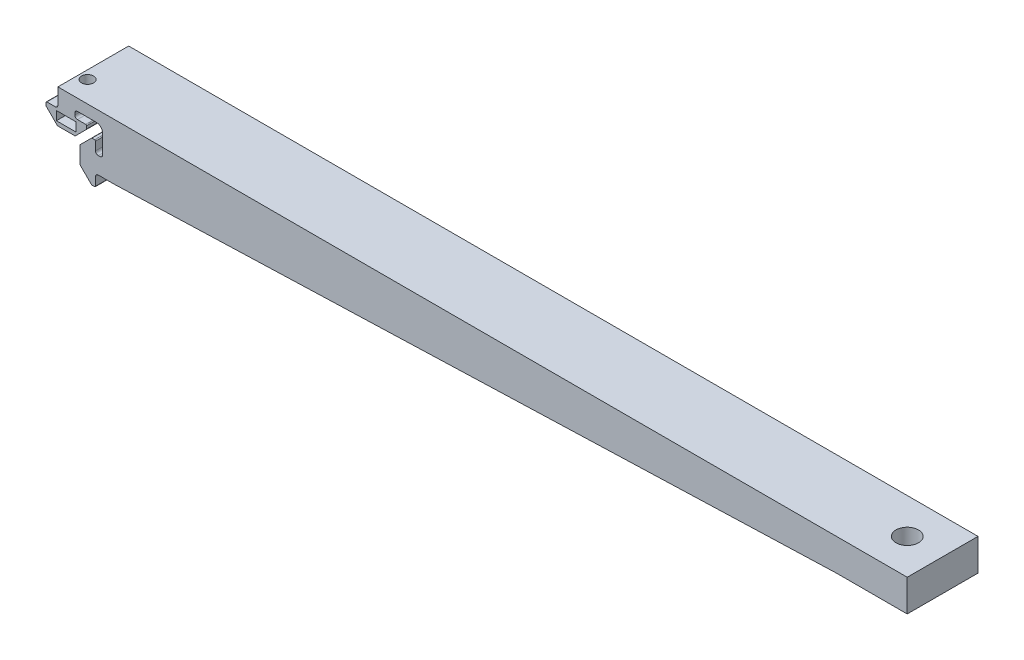
from build123d import *

# Parameters (mm, degrees)
BOSS_EXTRUDE1_DEPTH = 20
BOSS_EXTRUDE2_DEPTH = 20
CUT_EXTRUDE1_DEPTH  = 20
SKETCH4_R           = 3.175
CUT_EXTRUDE2_DEPTH  = 4
SKETCH5_W           = 20
SKETCH5_H           = 20
SKETCH5_R           = 3.175
BOSS_EXTRUDE3_DEPTH = 5
BOSS_EXTRUDE4_DEPTH = 20
CUT_EXTRUDE3_START  = -6
CUT_EXTRUDE3_DEPTH  = 2.5
SKETCH9_R           = 1.7
CUT_EXTRUDE4_DEPTH  = 20.237


with BuildPart() as part:
    # Sketch1 → Boss-Extrude1 (new body)
    with BuildSketch(Plane.XY):
        with BuildLine():
            ThreePointArc((-3.138, 8.25), (-2.60201306, 8.47201306), (-2.38, 9.008))
            Line((-2.38, 9.008), (-2.38, 9.492))
            Line((-2.38, 9.492), (-2.38, 13.492))
            Line((-2.38, 13.492), (13.492, 13.492))
            Line((13.492, 13.492), (13.492, -2.38))
            Line((13.492, -2.38), (9.492, -2.38))
            Line((9.492, -2.38), (9.008, -2.38))
            ThreePointArc((9.008, -2.38), (8.47201306, -2.60201306), (8.25, -3.138))
            Line((8.25, -3.138), (8.25, -5.487))
            ThreePointArc((8.25, -5.487), (8.17443355, -5.66943355), (7.992, -5.745))
            Line((7.992, -5.745), (7.266240833, -5.745))
            ThreePointArc((7.266240833, -5.745), (7.167508508, -5.725360919), (7.083807284, -5.66943355))
            Line((7.083807284, -5.66943355), (3.98056645, -2.566192716))
            ThreePointArc((3.98056645, -2.566192716), (3.924639081, -2.482491492), (3.905, -2.383759167))
            Line((3.905, -2.383759167), (3.905, 2.38407951))
            ThreePointArc((3.905, 2.38407951), (3.924639081, 2.482811836), (3.98056645, 2.56651306))
            Line((3.98056645, 2.56651306), (7.08348694, 5.66943355))
            ThreePointArc((7.08348694, 5.66943355), (7.167188164, 5.725360919), (7.26592049, 5.745))
            Line((7.26592049, 5.745), (7.992, 5.745))
            ThreePointArc((7.992, 5.745), (8.17443355, 5.66943355), (8.25, 5.487))
            Line((8.25, 5.487), (8.25, 3.138))
            ThreePointArc((8.25, 3.138), (8.47201306, 2.60201306), (9.008, 2.38))
            Line((9.008, 2.38), (9.492, 2.38))
            ThreePointArc((9.492, 2.38), (10.02798694, 2.60201306), (10.25, 3.138))
            Line((10.25, 3.138), (10.25, 8.5))
            ThreePointArc((10.25, 8.5), (9.737436867, 9.737436867), (8.5, 10.25))
            Line((8.5, 10.25), (3.138, 10.25))
            ThreePointArc((3.138, 10.25), (2.60201306, 10.02798694), (2.38, 9.492))
            Line((2.38, 9.492), (2.38, 9.008))
            ThreePointArc((2.38, 9.008), (2.60201306, 8.47201306), (3.138, 8.25))
            Line((3.138, 8.25), (5.487, 8.25))
            ThreePointArc((5.487, 8.25), (5.66943355, 8.17443355), (5.745, 7.992))
            Line((5.745, 7.992), (5.745, 7.266240833))
            ThreePointArc((5.745, 7.266240833), (5.725360919, 7.167508508), (5.66943355, 7.083807284))
            Line((5.66943355, 7.083807284), (2.566192716, 3.98056645))
            ThreePointArc((2.566192716, 3.98056645), (2.482491492, 3.924639081), (2.383759167, 3.905))
            Line((2.383759167, 3.905), (-2.38407951, 3.905))
            ThreePointArc((-2.38407951, 3.905), (-2.482811836, 3.924639081), (-2.56651306, 3.98056645))
            Line((-2.56651306, 3.98056645), (-5.66943355, 7.08348694))
            ThreePointArc((-5.66943355, 7.08348694), (-5.725360919, 7.167188164), (-5.745, 7.26592049))
            Line((-5.745, 7.26592049), (-5.745, 7.992))
            ThreePointArc((-5.745, 7.992), (-5.66943355, 8.17443355), (-5.487, 8.25))
            Line((-5.487, 8.25), (-3.138, 8.25))
        make_face()
    extrude(amount=-BOSS_EXTRUDE1_DEPTH)

    # Sketch2 → Boss-Extrude2 (add)
    with BuildSketch(Plane.XY):
        Polygon((13.492, 13.492), (237.62, 13.492), (237.62, 9.492), (13.492, -2.38), align=None)
    extrude(amount=-BOSS_EXTRUDE2_DEPTH)

    # Sketch3 → Cut-Extrude1 (cut)
    with BuildSketch(Plane.XY):
        Polygon((237.62, 9.492), (217.62, 9.492), (217.62, 8.432605368), align=None)
    extrude(amount=-CUT_EXTRUDE1_DEPTH, mode=Mode.SUBTRACT)

    # Sketch4 → Cut-Extrude2 (cut)
    with BuildSketch(Plane.XZ.offset(-9.492)):
        with Locations((227.62, -10)):
            Circle(SKETCH4_R)
    extrude(amount=-CUT_EXTRUDE2_DEPTH, mode=Mode.SUBTRACT)

    # Sketch5 → Boss-Extrude3 (add)
    with BuildSketch(Plane.XZ.offset(-9.492)):
        with Locations((227.62, -10)):
            Rectangle(SKETCH5_W, SKETCH5_H)
        with Locations((227.62, -10)):
            Circle(SKETCH5_R, mode=Mode.SUBTRACT)
    extrude(amount=BOSS_EXTRUDE3_DEPTH)

    # Sketch6 → Boss-Extrude4 (add)
    with BuildSketch(Plane.XY):
        Polygon((13.492, -2.38), (217.62, 4.492), (217.62, 8.432605368), align=None)
    extrude(amount=-BOSS_EXTRUDE4_DEPTH)

    # Sketch8 → Cut-Extrude3 (cut)
    with BuildSketch(Plane(origin=(0, 13.492, 0), x_dir=(1, 0, 0), z_dir=(0, 1, 0)).offset(CUT_EXTRUDE3_START)):
        Polygon((2.383759167, 0), (-2.38407951, 0), (-2.800160172, 0), (-2.800160172, 4.383419246), (-2.800160172, 7.616580754), (-0.000160172, 9.233161507), (2.799839828, 7.616580754), (2.799839828, 4.383419246), (2.799839828, 0), align=None)
    extrude(amount=-CUT_EXTRUDE3_DEPTH, mode=Mode.SUBTRACT)

    # Sketch9 → Cut-Extrude4 (cut, through all)
    with BuildSketch(Plane(origin=(0, 13.492, 0), x_dir=(1, 0, 0), z_dir=(0, 1, 0))):
        with Locations((-0.000160172, 6)):
            Circle(SKETCH9_R)
    extrude(amount=-CUT_EXTRUDE4_DEPTH, mode=Mode.SUBTRACT)


solid = part.part
